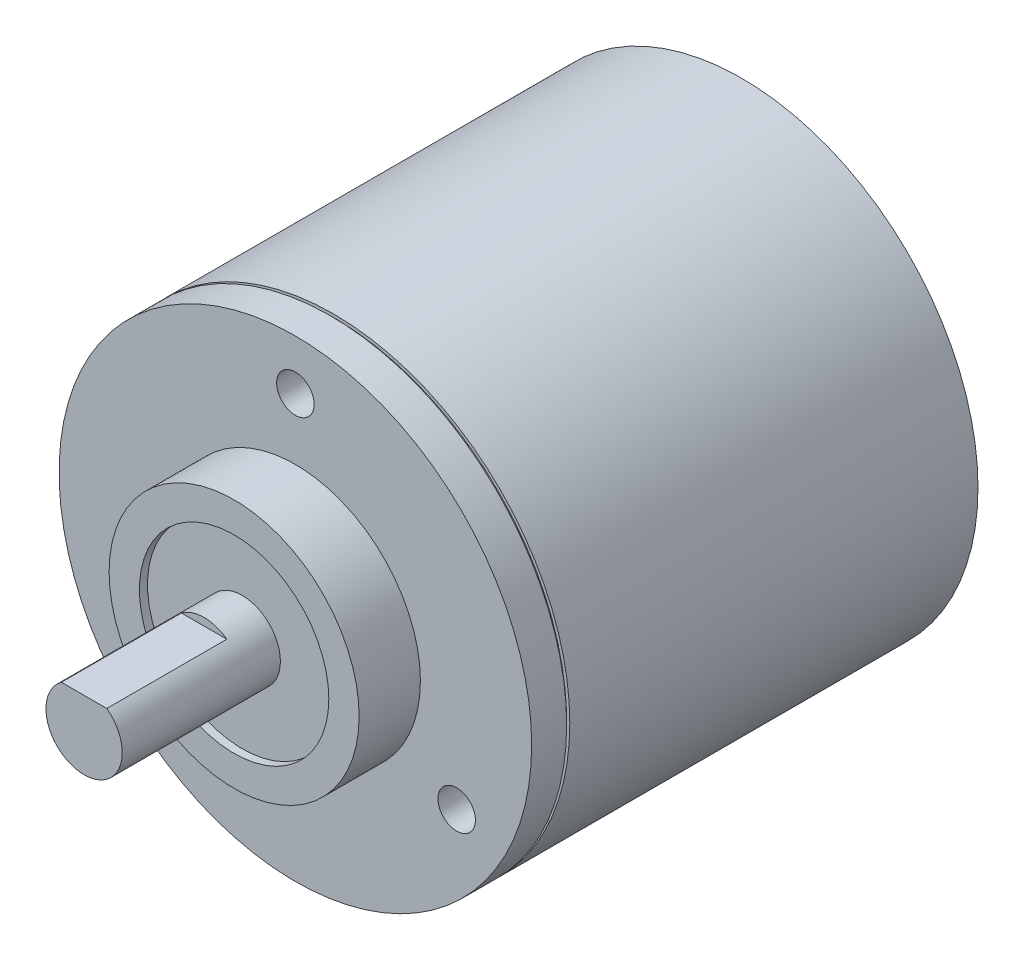
from build123d import *

# Parameters (mm, degrees)
ESQUISSE1_R                  = 18.9
BOSS_EXTRU_1_DEPTH           = 35.6
BOSS_EXTRU_1_DEPTH_BACK      = 0.1
ESQUISSE3_R                  = 10
BOSS_EXTRU_3_DEPTH           = 4.9
ESQUISSE4_R                  = 3.05
BOSS_EXTRU_4_DEPTH           = 12
ESQUISSE5_R                  = 1.5
ENL_V_MAT_EXTRU_1_DEPTH      = 8
ESQUISSE6_R                  = 7.575
ESQUISSE6_R_2                = 3.05
ENL_V_MAT_EXTRU_3_DEPTH      = 0.65
ENL_V_MAT_EXTRU_4_DEPTH      = 9.6
R_P_TITION_CIRCULAIRE1_COUNT = 3
ESQUISSE8_W                  = 0.25
ESQUISSE8_H                  = 3.196164938


with BuildPart() as part:
    # Esquisse1 → Boss.-Extru.1 (new body, two sides)
    with BuildSketch(Plane.XY) as boss_extru_1_sk:
        Circle(ESQUISSE1_R)
    extrude(amount=BOSS_EXTRU_1_DEPTH)
    extrude(boss_extru_1_sk.sketch, amount=-BOSS_EXTRU_1_DEPTH_BACK)

    # Esquisse3 → Boss.-Extru.3 (add)
    with BuildSketch(Plane.XY.offset(35.6)):
        Circle(ESQUISSE3_R)
    extrude(amount=BOSS_EXTRU_3_DEPTH)

    # Esquisse4 → Boss.-Extru.4 (add)
    with BuildSketch(Plane.XY.offset(40.5)):
        Circle(ESQUISSE4_R)
    extrude(amount=BOSS_EXTRU_4_DEPTH)

    # Esquisse5 → Enlèv. mat.-Extru.1 (cut)
    with BuildSketch(Plane.XY.offset(35.6)):
        with Locations((0, 14.9)):
            Circle(ESQUISSE5_R)
    enl_v_mat_extru_1 = extrude(amount=-ENL_V_MAT_EXTRU_1_DEPTH, mode=Mode.SUBTRACT)

    # Esquisse6 → Enlèv. mat.-Extru.3 (cut)
    with BuildSketch(Plane.XY.offset(40.5)):
        Circle(ESQUISSE6_R)
        Circle(ESQUISSE6_R_2, mode=Mode.SUBTRACT)
    extrude(amount=-ENL_V_MAT_EXTRU_3_DEPTH, mode=Mode.SUBTRACT)

    # Esquisse7 → Enlèv. mat.-Extru.4 (cut)
    with BuildSketch(Plane.XY.offset(52.5)):
        Polygon((-4.317069663, 2.45), (4.517863601, 2.45), (1.480855292, 5.48700831), (-3.363298459, 5.48700831), align=None)
    extrude(amount=-ENL_V_MAT_EXTRU_4_DEPTH, mode=Mode.SUBTRACT)

    # Répétition circulaire1: Enlèv. mat.-Extru.1 ×3 about axis
    r_p_tition_circulaire1_axis = Axis((0, 0, 0), (0, 0, 1))
    for i in range(1, R_P_TITION_CIRCULAIRE1_COUNT):
        add(enl_v_mat_extru_1.rotate(r_p_tition_circulaire1_axis, i * 360 / R_P_TITION_CIRCULAIRE1_COUNT), mode=Mode.SUBTRACT)

    # Esquisse8 → Enlèvement de matière-Révolution1 (revolve, cut)
    with BuildSketch(Plane(origin=(0, 0, 0), x_dir=(0, 0, -1), z_dir=(1, 0, 0))):
        with Locations((-32.675, 20.248082469)):
            Rectangle(ESQUISSE8_W, ESQUISSE8_H)
    revolve(axis=Axis((0, 0, -0.1), (0, 0, 1)), mode=Mode.SUBTRACT)


solid = part.part
